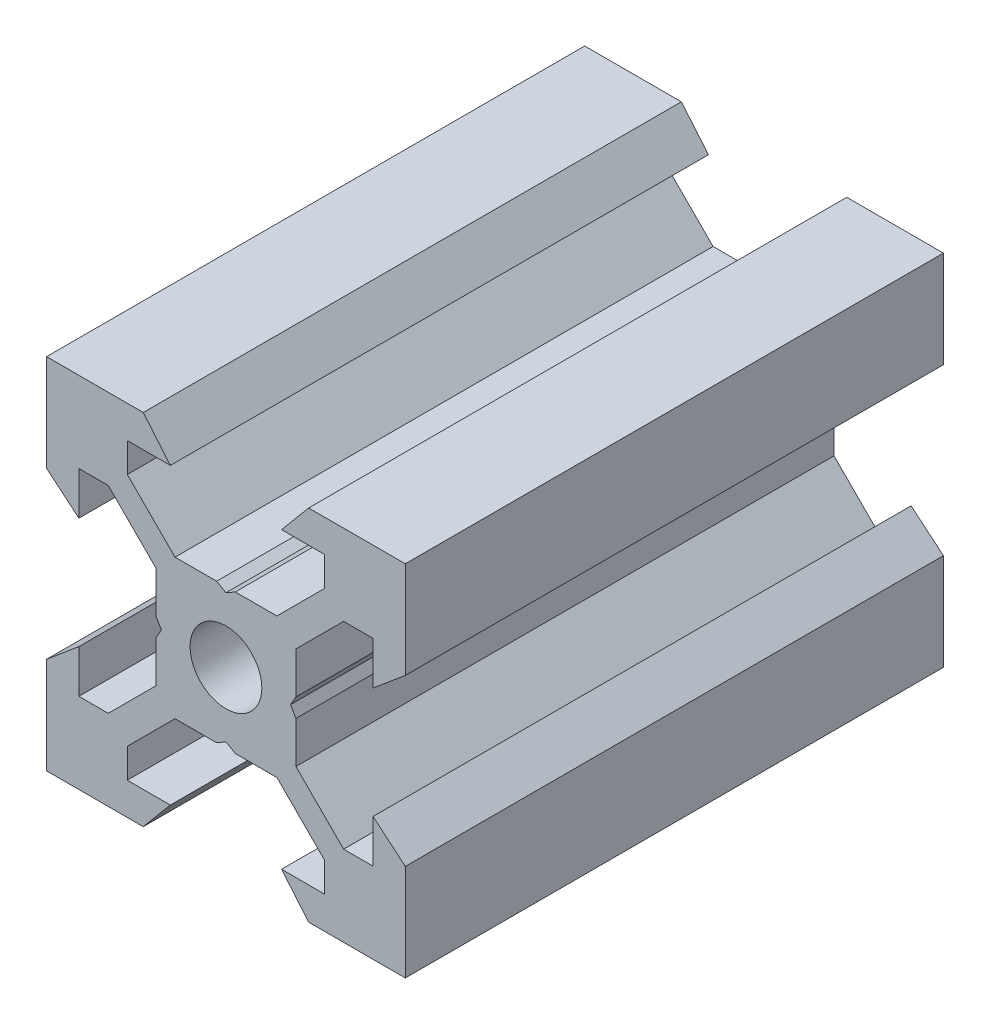
from build123d import *

# Parameters (mm, degrees)
SKETCH1_R           = 2
BOSS_EXTRUDE1_DEPTH = 15


with BuildPart() as part:
    # Sketch1 → Boss-Extrude1 (new body, symmetric)
    with BuildSketch(Plane.XY):
        Polygon((10, 10), (10, 4.610379336), (8.2, 3.1), (8.2, 5.5), (6.560660172, 5.5), (3.9, 2.839339828), (3.9, 0.519615242), (3.6, 0), (3.9, -0.519615242), (3.9, -2.839339828), (6.560660172, -5.5), (8.2, -5.5), (8.2, -3.1), (10, -4.610379336), (10, -10), (4.610379336, -10), (3.1, -8.2), (5.5, -8.2), (5.5, -6.560660172), (2.839339828, -3.9), (0.519615242, -3.9), (0, -3.6), (-0.519615242, -3.9), (-2.839339828, -3.9), (-5.5, -6.560660172), (-5.5, -8.2), (-3.1, -8.2), (-4.610379336, -10), (-10, -10), (-10, -4.610379336), (-8.2, -3.1), (-8.2, -5.5), (-6.560660172, -5.5), (-3.9, -2.839339828), (-3.9, -0.519615242), (-3.6, 0), (-3.9, 0.519615242), (-3.9, 2.839339828), (-6.560660172, 5.5), (-8.2, 5.5), (-8.2, 3.1), (-10, 4.610379336), (-10, 10), (-4.610379336, 10), (-3.1, 8.2), (-5.5, 8.2), (-5.5, 6.560660172), (-2.839339828, 3.9), (-0.519615242, 3.9), (0, 3.6), (0.519615242, 3.9), (2.839339828, 3.9), (5.5, 6.560660172), (5.5, 8.2), (3.1, 8.2), (4.610379336, 10), align=None)
        Circle(SKETCH1_R, mode=Mode.SUBTRACT)
    extrude(amount=BOSS_EXTRUDE1_DEPTH, both=True)


solid = part.part
